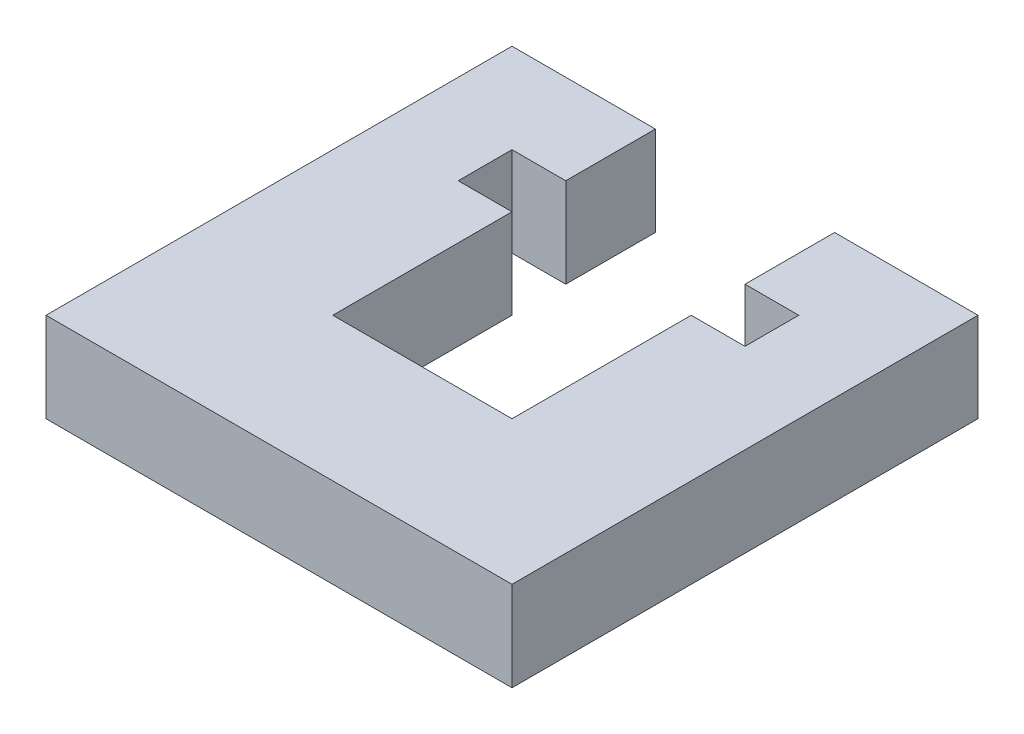
from build123d import *

# Parameters (mm, degrees)
EXTRUDE_1_DEPTH = 5


with BuildPart() as part:
    # 草图1 → 凸台-拉伸1 (new body)
    with BuildSketch(Plane(origin=(0, 0, 0), x_dir=(1, 0, 0), z_dir=(0, 1, 0))):
        Polygon((0, 26), (0, 0), (26, 0), (26, 26), (18, 26), (18, 21), (21, 21), (21, 18), (18, 18), (18, 8), (8, 8), (8, 18), (5, 18), (5, 21), (8, 21), (8, 26), align=None)
    extrude(amount=EXTRUDE_1_DEPTH)


solid = part.part
